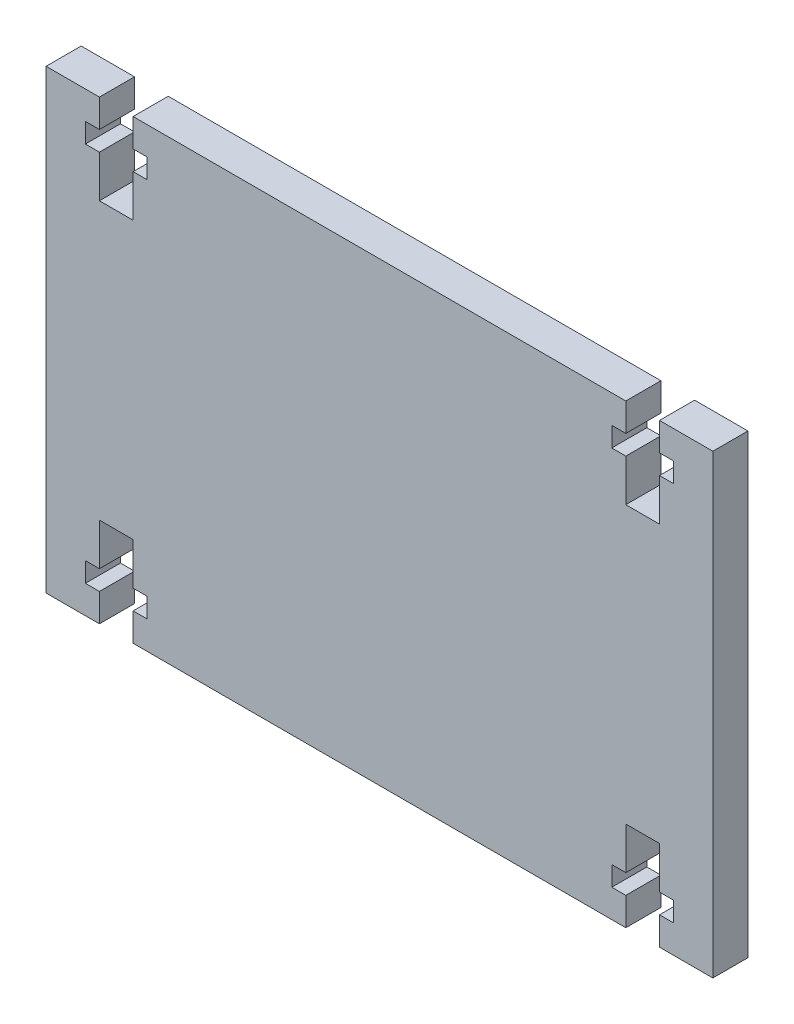
from build123d import *

# Parameters (mm, degrees)
BOSS_EXTRUDE1_DEPTH = 5


with BuildPart() as part:
    # Sketch1 → Boss-Extrude1 (new body)
    with BuildSketch(Plane.XY):
        Polygon((-47.5, 32.5), (-39.9, 32.5), (-39.9, 28.5), (-41.9, 28.5), (-41.9, 25.7), (-39.9, 25.7), (-39.9, 19.7), (-35.1, 19.7), (-35.1, 25.7), (-33.1, 25.7), (-33.1, 28.5), (-35.1, 28.5), (-35.1, 32.5), (35.1, 32.5), (35.1, 28.5), (33.1, 28.5), (33.1, 25.7), (35.1, 25.7), (35.1, 19.7), (39.9, 19.7), (39.9, 25.7), (41.9, 25.7), (41.9, 28.5), (39.9, 28.5), (39.9, 32.5), (47.5, 32.5), (47.5, -32.5), (39.9, -32.5), (39.9, -28.5), (41.9, -28.5), (41.9, -25.7), (39.9, -25.7), (39.9, -19.7), (35.1, -19.7), (35.1, -25.7), (33.1, -25.7), (33.1, -28.5), (35.1, -28.5), (35.1, -32.5), (-35.1, -32.5), (-35.1, -28.5), (-33.1, -28.5), (-33.1, -25.7), (-35.1, -25.7), (-35.1, -19.7), (-39.9, -19.7), (-39.9, -25.7), (-41.9, -25.7), (-41.9, -28.5), (-39.9, -28.5), (-39.9, -32.5), (-47.5, -32.5), align=None)
    extrude(amount=BOSS_EXTRUDE1_DEPTH)


solid = part.part
